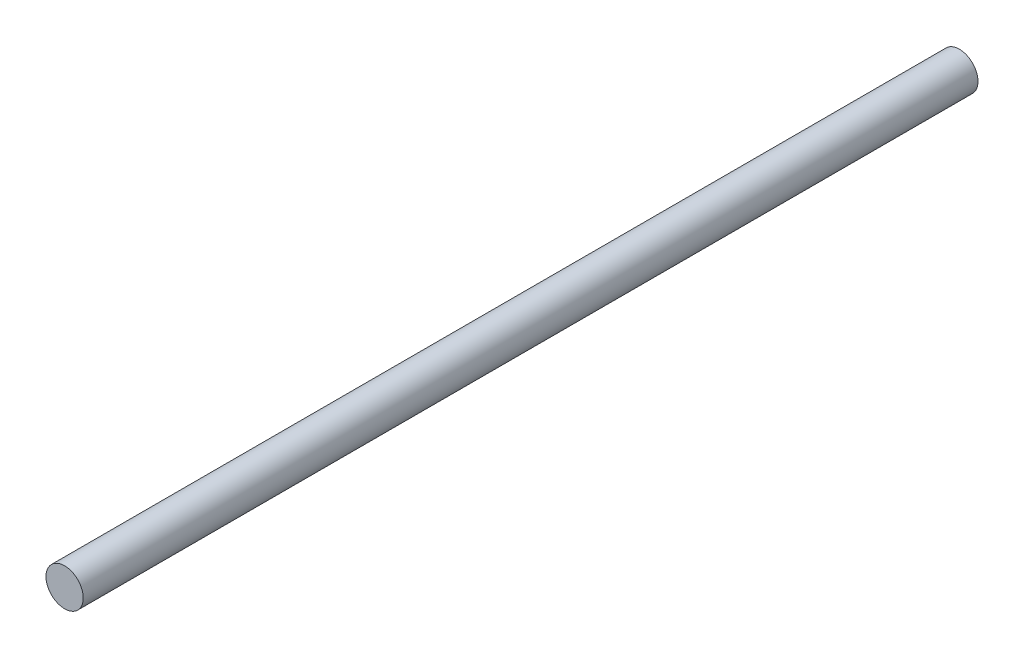
from build123d import *

# Parameters (mm, degrees)
SKETCH1_R           = 15.875
BOSS_EXTRUDE1_DEPTH = 762


with BuildPart() as part:
    # Sketch1 → Boss-Extrude1 (new body)
    with BuildSketch(Plane.XY):
        Circle(SKETCH1_R)
    extrude(amount=BOSS_EXTRUDE1_DEPTH)


solid = part.part
